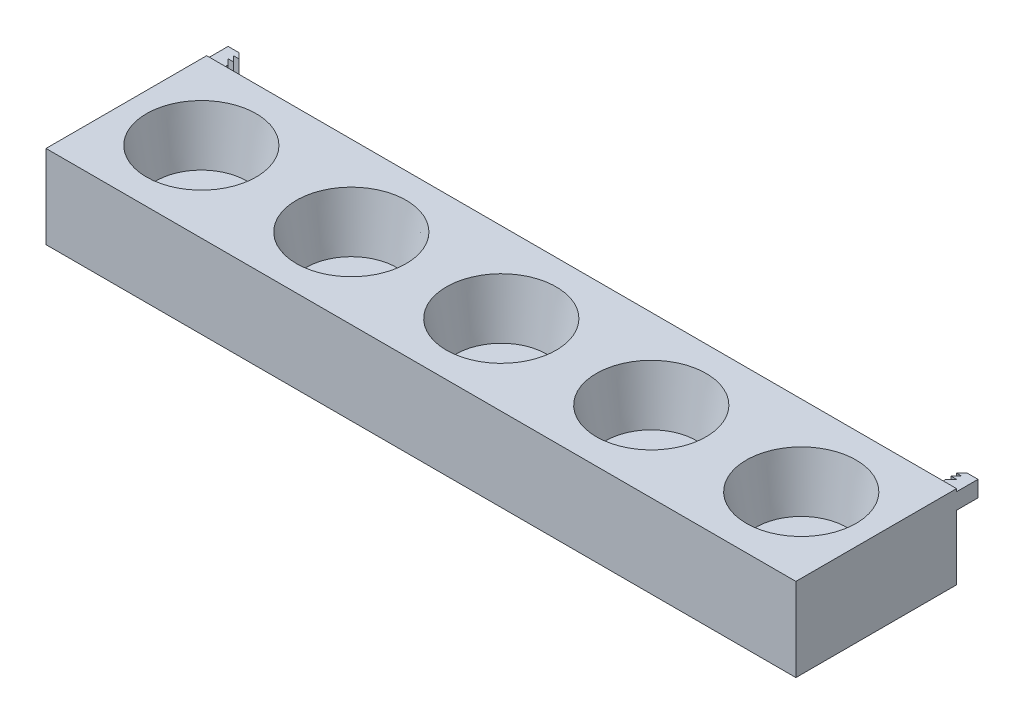
from build123d import *

# Parameters (mm, degrees)
SKETCH1_W                = 700
SKETCH1_H                = 150
BOSS_EXTRUDE1_DEPTH      = 20
BOSS_EXTRUDE1_DEPTH_BACK = 57.8
SKETCH3_W                = 15
SKETCH3_H                = 15
BOSS_EXTRUDE2_DEPTH      = 20
CUT_EXTRUDE1_DEPTH       = 15
CUT_EXTRUDE2_DEPTH       = 15
SKETCH6_R                = 51.25
CUT_EXTRUDE3_DEPTH       = 50
CUT_EXTRUDE3_TAPER       = 10
SKETCH7_R                = 51.25
CUT_EXTRUDE4_DEPTH       = 50
CUT_EXTRUDE4_TAPER       = 10
SKETCH8_R                = 51.25
CUT_EXTRUDE5_DEPTH       = 50
CUT_EXTRUDE5_TAPER       = 10
SKETCH9_R                = 51.25
CUT_EXTRUDE6_DEPTH       = 50
CUT_EXTRUDE6_TAPER       = 10
SKETCH10_R               = 51.25
CUT_EXTRUDE7_DEPTH       = 50
CUT_EXTRUDE7_TAPER       = 10


with BuildPart() as part:
    # Sketch1 → Boss-Extrude1 (new body, two sides)
    with BuildSketch(Plane(origin=(0, 0, 0), x_dir=(1, 0, 0), z_dir=(0, 1, 0))) as boss_extrude1_sk:
        Rectangle(SKETCH1_W, SKETCH1_H)
    extrude(amount=BOSS_EXTRUDE1_DEPTH)
    extrude(boss_extrude1_sk.sketch, amount=-BOSS_EXTRUDE1_DEPTH_BACK)

    # Sketch3 → Boss-Extrude2 (add)
    with BuildSketch(Plane(origin=(0, 0, -75), x_dir=(-1, 0, 0), z_dir=(0, 0, -1))):
        with Locations((-342.5, 10)):
            Rectangle(SKETCH3_W, SKETCH3_H)
        with Locations((342.5, 10)):
            Rectangle(SKETCH3_W, SKETCH3_H)
    extrude(amount=BOSS_EXTRUDE2_DEPTH)

    # Sketch4 → Cut-Extrude1 (cut)
    with BuildSketch(Plane(origin=(0, 17.5, 0), x_dir=(1, 0, 0), z_dir=(0, 1, 0))):
        Polygon((340, 90), (335, 90), (335, 85), align=None)
        Polygon((340, 85), (335, 85), (335, 80), align=None)
        Polygon((335, 95), (335, 90), (340, 95), align=None)
    extrude(amount=-CUT_EXTRUDE1_DEPTH, mode=Mode.SUBTRACT)

    # Sketch5 → Cut-Extrude2 (cut)
    with BuildSketch(Plane(origin=(0, 17.5, 0), x_dir=(1, 0, 0), z_dir=(0, 1, 0))):
        Polygon((-335, 85), (-335, 90), (-340, 90), align=None)
        Polygon((-335, 90), (-335, 95), (-340, 95), align=None)
        Polygon((-335, 80), (-335, 85), (-340, 85), align=None)
    extrude(amount=-CUT_EXTRUDE2_DEPTH, mode=Mode.SUBTRACT)

    # Sketch6 → Cut-Extrude3 (cut)
    with BuildSketch(Plane(origin=(0, 20, 0), x_dir=(1, 0, 0), z_dir=(0, 1, 0))):
        Circle(SKETCH6_R)
    extrude(amount=-CUT_EXTRUDE3_DEPTH, taper=CUT_EXTRUDE3_TAPER, mode=Mode.SUBTRACT)

    # Sketch7 → Cut-Extrude4 (cut)
    with BuildSketch(Plane(origin=(0, 20, 0), x_dir=(1, 0, 0), z_dir=(0, 1, 0))):
        with Locations((140, 0)):
            Circle(SKETCH7_R)
    extrude(amount=-CUT_EXTRUDE4_DEPTH, taper=CUT_EXTRUDE4_TAPER, mode=Mode.SUBTRACT)

    # Sketch8 → Cut-Extrude5 (cut)
    with BuildSketch(Plane(origin=(0, 20, 0), x_dir=(1, 0, 0), z_dir=(0, 1, 0))):
        with Locations((280, 0)):
            Circle(SKETCH8_R)
    extrude(amount=-CUT_EXTRUDE5_DEPTH, taper=CUT_EXTRUDE5_TAPER, mode=Mode.SUBTRACT)

    # Sketch9 → Cut-Extrude6 (cut)
    with BuildSketch(Plane(origin=(0, 20, 0), x_dir=(1, 0, 0), z_dir=(0, 1, 0))):
        with Locations((-140, 0)):
            Circle(SKETCH9_R)
    extrude(amount=-CUT_EXTRUDE6_DEPTH, taper=CUT_EXTRUDE6_TAPER, mode=Mode.SUBTRACT)

    # Sketch10 → Cut-Extrude7 (cut)
    with BuildSketch(Plane(origin=(0, 20, 0), x_dir=(1, 0, 0), z_dir=(0, 1, 0))):
        with Locations((-280, 0)):
            Circle(SKETCH10_R)
    extrude(amount=-CUT_EXTRUDE7_DEPTH, taper=CUT_EXTRUDE7_TAPER, mode=Mode.SUBTRACT)


solid = part.part
